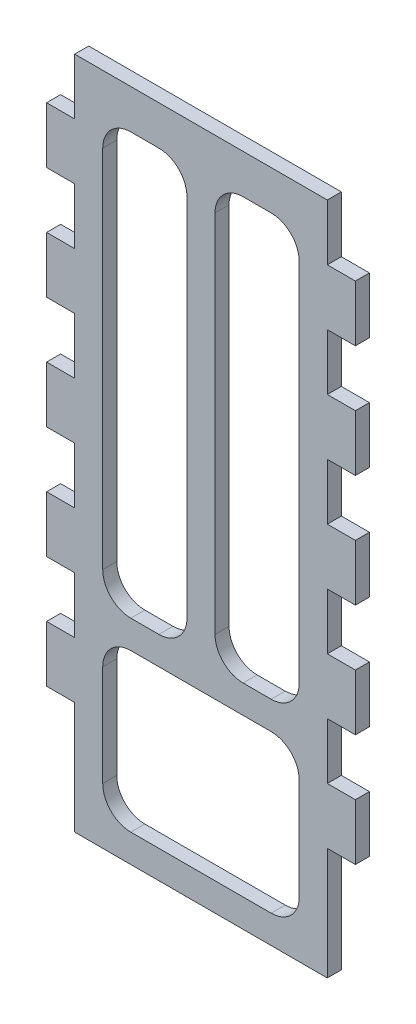
from build123d import *

# Parameters (mm, degrees)
SKETCH1_W           = 57.15
SKETCH1_H           = 152.4
BOSS_EXTRUDE1_DEPTH = 3.175
SKETCH2_W           = 6.35
SKETCH2_H           = 12.7
BOSS_EXTRUDE2_DEPTH = 3.175
LPATTERN1_COUNT     = 5
LPATTERN1_PITCH     = 25.4
SKETCH3_W           = 44.45
SKETCH3_H           = 35.56
CUT_EXTRUDE1_DEPTH  = 3.175
SKETCH4_W           = 19.05
SKETCH4_H           = 95.25
CUT_EXTRUDE2_DEPTH  = 3.175
FILLET1_R           = 6.35


with BuildPart() as part:
    # Sketch1 → Boss-Extrude1 (new body)
    with BuildSketch(Plane.XY):
        with Locations((28.575, 76.2)):
            Rectangle(SKETCH1_W, SKETCH1_H)
    extrude(amount=BOSS_EXTRUDE1_DEPTH)

    # Sketch2 → Boss-Extrude2 (add)
    with BuildSketch(Plane.XY.offset(3.175)):
        with Locations((-3.175, 133.35)):
            Rectangle(SKETCH2_W, SKETCH2_H)
        with Locations((60.325, 133.35)):
            Rectangle(SKETCH2_W, SKETCH2_H)
    boss_extrude2 = extrude(amount=-BOSS_EXTRUDE2_DEPTH)

    # LPattern1: Boss-Extrude2 ×5
    with Locations(*[(0, -i * LPATTERN1_PITCH, 0) for i in range(1, LPATTERN1_COUNT)]):
        add(boss_extrude2)

    # Sketch3 → Cut-Extrude1 (cut)
    with BuildSketch(Plane.XY.offset(3.175)):
        with Locations((28.575, 24.13)):
            Rectangle(SKETCH3_W, SKETCH3_H)
    extrude(amount=-CUT_EXTRUDE1_DEPTH, mode=Mode.SUBTRACT)

    # Sketch4 → Cut-Extrude2 (cut)
    with BuildSketch(Plane.XY.offset(3.175)):
        with Locations((15.875, 95.885)):
            Rectangle(SKETCH4_W, SKETCH4_H)
        with Locations((41.275, 95.885)):
            Rectangle(SKETCH4_W, SKETCH4_H)
    extrude(amount=-CUT_EXTRUDE2_DEPTH, mode=Mode.SUBTRACT)

    # Fillet1
    fillet1_edges = [part.edges().sort_by_distance(p)[0] for p in [
        (6.35, 6.35, 1.5875),
        (6.35, 41.91, 1.5875),
        (50.8, 41.91, 1.5875),
        (50.8, 6.35, 1.5875),
        (6.35, 48.26, 1.5875),
        (6.35, 143.51, 1.5875),
        (25.4, 143.51, 1.5875),
        (25.4, 48.26, 1.5875),
        (31.75, 48.26, 1.5875),
        (31.75, 143.51, 1.5875),
        (50.8, 143.51, 1.5875),
        (50.8, 48.26, 1.5875),
    ]]
    fillet(fillet1_edges, radius=FILLET1_R)


solid = part.part
